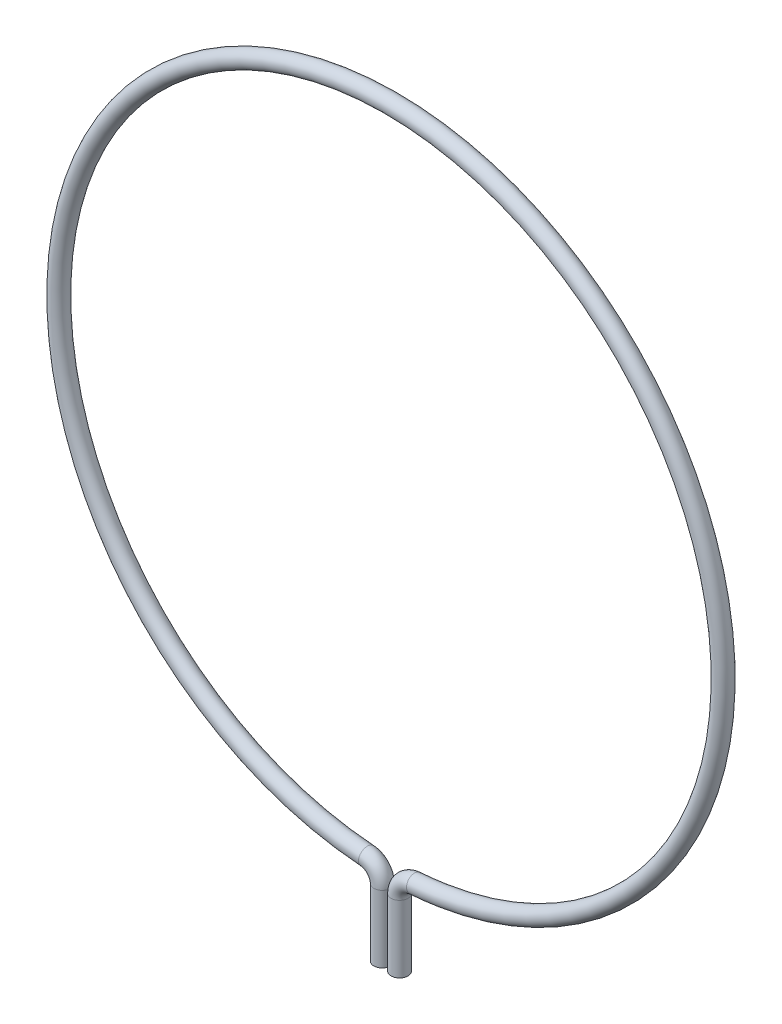
from build123d import *

# Parameters (mm, degrees)
SKETCH2_R = 0.6477


with BuildPart() as part:
    # Sweep2: sweep along a path in Sketch1
    with BuildLine(Plane.XY) as sweep2_path:
        Line((-0.6604, -31.741413349), (-0.6604, -26.600046162))
        ThreePointArc((-0.6604, -26.600046162), (-1.000442141, -25.735130917), (-1.83847619, -25.333377297))
        ThreePointArc((-1.83847619, -25.333377297), (0, 25.4), (1.83847619, -25.333377297))
        ThreePointArc((1.83847619, -25.333377297), (1.000442141, -25.735130917), (0.6604, -26.600046162))
        Line((0.6604, -26.600046162), (0.6604, -31.741413349))
    # Sketch2 → Sweep2 (sweep)
    with BuildSketch(Plane(origin=(0, -31.741413349, 0), x_dir=(1, 0, 0), z_dir=(0, 1, 0))):
        with Locations((0.6604, 0)):
            Circle(SKETCH2_R)
    sweep(path=sweep2_path.line)


solid = part.part
